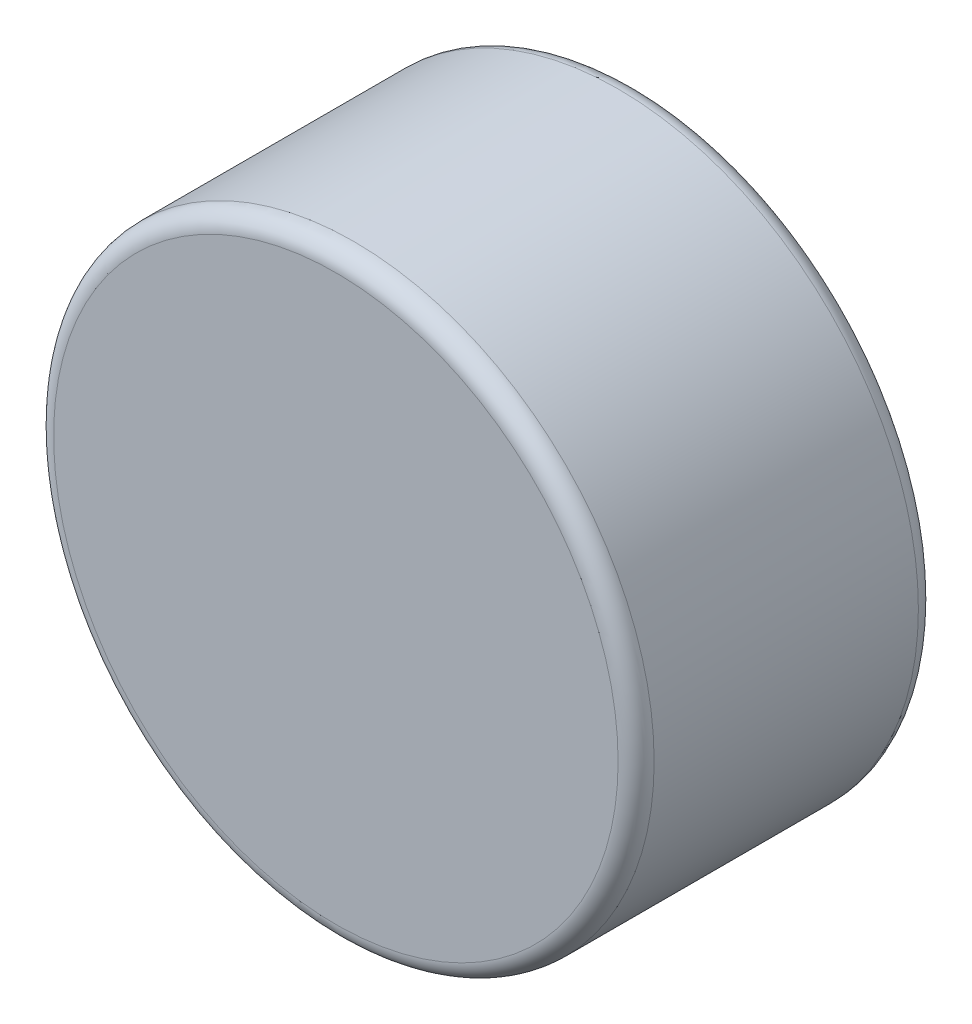
from build123d import *

# Parameters (mm, degrees)
SKETCH1_R           = 5
BOSS_EXTRUDE1_DEPTH = 5
FILLET1_R           = 0.3


with BuildPart() as part:
    # Sketch1 → Boss-Extrude1 (new body)
    with BuildSketch(Plane.XY):
        Circle(SKETCH1_R)
    extrude(amount=BOSS_EXTRUDE1_DEPTH)

    # Fillet1
    fillet1_edges = [part.edges().sort_by_distance(p)[0] for p in [
        (-5, 0, 0),
        (-5, 0, 5),
    ]]
    fillet(fillet1_edges, radius=FILLET1_R)


solid = part.part
